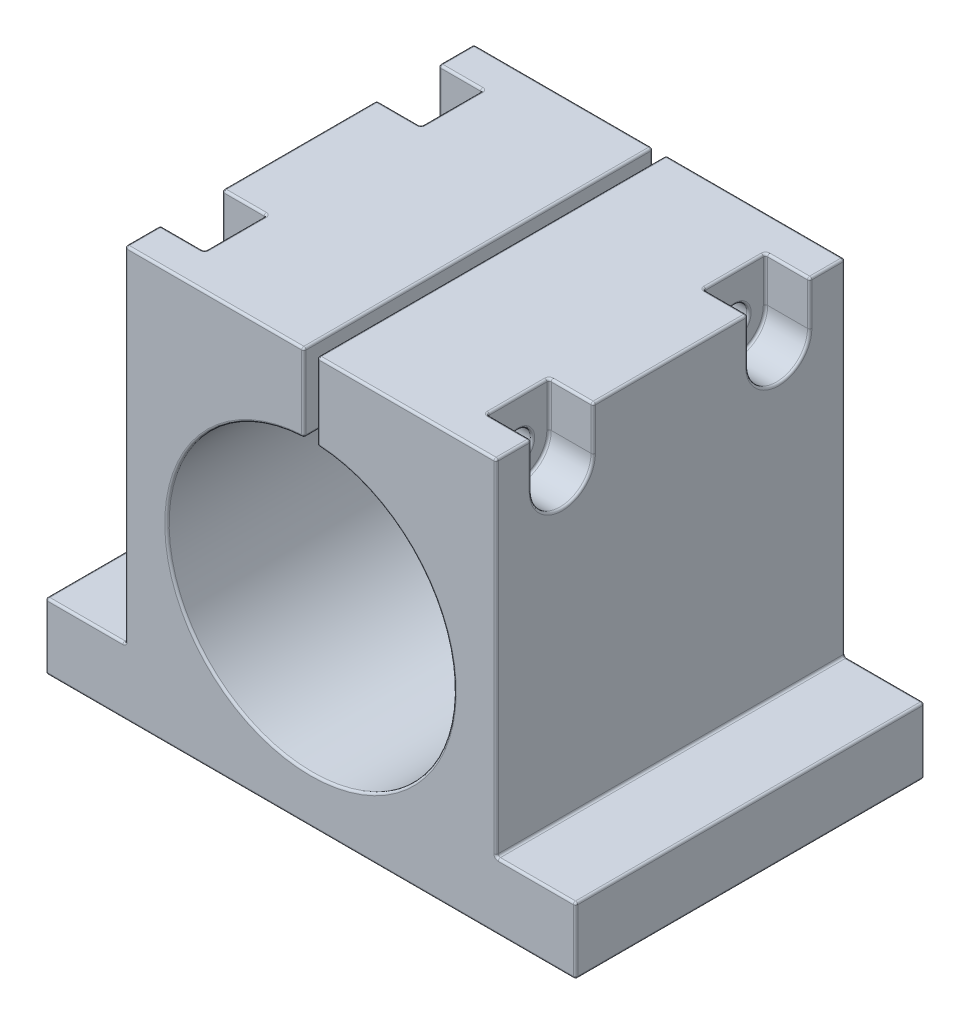
from build123d import *

# Parameters (mm, degrees)
EXTRUDE_1_DEPTH     = 39.5
CUT_EXTRUDE_1_DEPTH = 10
CUT_EXTRUDE_2_DEPTH = 10
SKETCH_4_R          = 3.25
CUT_EXTRUDE_3_DEPTH = 93
FILLET_1_R          = 0.5


with BuildPart() as part:
    # Эскиз1 → Бобышка-Вытянуть1 (new body, symmetric)
    with BuildSketch(Plane.XY):
        with BuildLine():
            Line((-60, -43), (60, -43))
            Line((60, -43), (60, -28))
            Line((60, -28), (42, -28))
            Line((42, -28), (42, 50))
            Line((42, 50), (1.5, 50))
            Line((1.5, 50), (1.5, 32.465366161))
            ThreePointArc((1.5, 32.465366161), (23.505318547, 22.444375687), (32.5, 0))
            ThreePointArc((32.5, 0), (-22.444375687, -23.505318547), (-1.5, 32.465366161))
            Line((-1.5, 32.465366161), (-1.5, 50))
            Line((-1.5, 50), (-42, 50))
            Line((-42, 50), (-42, -28))
            Line((-42, -28), (-60, -28))
            Line((-60, -28), (-60, -43))
        make_face()
    extrude(amount=EXTRUDE_1_DEPTH, both=True)

    # Эскиз2 → Вырез-Вытянуть1 (cut)
    with BuildSketch(Plane.ZY.offset(42)):
        with BuildLine():
            ThreePointArc((-17.5, 40), (-24.5, 47), (-31.5, 40))
            Line((-31.5, 40), (-17.5, 40))
        make_face()
        with BuildLine():
            Line((-17.5, 40), (-31.5, 40))
            ThreePointArc((-31.5, 40), (-24.5, 33), (-17.5, 40))
        make_face()
        with BuildLine():
            Line((-17.5, 50), (-31.5, 50))
            Line((-31.5, 50), (-31.5, 40))
            ThreePointArc((-31.5, 40), (-24.5, 47), (-17.5, 40))
            Line((-17.5, 40), (-17.5, 50))
        make_face()
        with BuildLine():
            ThreePointArc((31.5, 40), (24.5, 47), (17.5, 40))
            Line((17.5, 40), (31.5, 40))
        make_face()
        with BuildLine():
            Line((31.5, 40), (17.5, 40))
            ThreePointArc((17.5, 40), (24.5, 33), (31.5, 40))
        make_face()
        with BuildLine():
            ThreePointArc((31.5, 40), (24.5, 47), (17.5, 40))
            Line((17.5, 40), (31.5, 40))
        make_face()
        with BuildLine():
            Line((31.5, 40), (17.5, 40))
            ThreePointArc((17.5, 40), (24.5, 33), (31.5, 40))
        make_face()
        with BuildLine():
            Line((31.5, 50), (17.5, 50))
            Line((17.5, 50), (17.5, 40))
            ThreePointArc((17.5, 40), (24.5, 47), (31.5, 40))
            Line((31.5, 40), (31.5, 50))
        make_face()
    extrude(amount=-CUT_EXTRUDE_1_DEPTH, mode=Mode.SUBTRACT)

    # Эскиз3 → Вырез-Вытянуть2 (cut)
    with BuildSketch(Plane(origin=(42, 0, 0), x_dir=(0, 0, -1), z_dir=(1, 0, 0))):
        with BuildLine():
            Line((-31.5, 50), (-31.5, 40))
            ThreePointArc((-31.5, 40), (-24.5, 33), (-17.5, 40))
            Line((-17.5, 40), (-17.5, 50))
            Line((-17.5, 50), (-31.5, 50))
        make_face()
        with BuildLine():
            Line((17.5, 50), (17.5, 40))
            ThreePointArc((17.5, 40), (24.5, 33), (31.5, 40))
            Line((31.5, 40), (31.5, 50))
            Line((31.5, 50), (17.5, 50))
        make_face()
    extrude(amount=-CUT_EXTRUDE_2_DEPTH, mode=Mode.SUBTRACT)

    # Эскиз4 → Вырез-Вытянуть3 (cut, through all)
    with BuildSketch(Plane.ZY.offset(32)):
        with Locations((-24.5, 40)):
            Circle(SKETCH_4_R)
        with Locations((24.5, 40)):
            Circle(SKETCH_4_R)
    extrude(amount=-CUT_EXTRUDE_3_DEPTH, mode=Mode.SUBTRACT)

    # Скругление1
    fillet_1_edges = [part.edges().sort_by_distance(p)[0] for p in [
        (32, 40, 21.25),
        (-32, 40, 21.25),
        (1.5, 41.232683081, -39.5),
        (-21.75, 50, 39.5),
        (21.75, 50, -39.5),
        (42, 11, -39.5),
        (51, -28, -39.5),
        (60, -35.5, -39.5),
        (0, -43, -39.5),
        (-60, -35.5, -39.5),
        (-51, -28, -39.5),
        (-42, 11, -39.5),
        (-42, 11, 39.5),
        (-21.75, 50, -39.5),
        (-1.5, 41.232683081, -39.5),
        (0, -32.5, -39.5),
        (-51, -28, 39.5),
        (1.5, 32.465366161, 0),
        (1.5, 50, 0),
        (42, 50, 35.5),
        (42, -28, 0),
        (60, -28, 0),
        (60, -43, 0),
        (-60, -43, 0),
        (-60, -28, 0),
        (-42, -28, 0),
        (-42, 50, 35.5),
        (-1.5, 50, 0),
        (-1.5, 32.465366161, 0),
        (-60, -35.5, 39.5),
        (0, -43, 39.5),
        (60, -35.5, 39.5),
        (-42, 50, 0),
        (51, -28, 39.5),
        (-32, 33, 24.5),
        (-32, 45, 17.5),
        (-32, 50, 24.5),
        (-37, 50, 17.5),
        (-42, 45, 31.5),
        (42, 11, 39.5),
        (-37, 50, 31.5),
        (-32, 45, 31.5),
        (-42, 33, 24.5),
        (-42, 45, 17.5),
        (21.75, 50, 39.5),
        (1.5, 41.232683081, 39.5),
        (-42, 50, -35.5),
        (0, -32.5, 39.5),
        (-32, 33, -24.5),
        (-42, 33, -24.5),
        (-42, 45, -31.5),
        (-32, 45, -17.5),
        (-32, 50, -24.5),
        (-37, 50, -31.5),
        (-42, 45, -17.5),
        (-37, 50, -17.5),
        (-32, 45, -31.5),
        (42, 50, 0),
        (32, 33, 24.5),
        (32, 45, 31.5),
        (32, 50, 24.5),
        (37, 50, 31.5),
        (32, 45, 17.5),
        (37, 50, 17.5),
        (42, 33, 24.5),
        (42, 45, 17.5),
        (42, 45, 31.5),
        (42, 50, -35.5),
        (32, 33, -24.5),
        (32, 45, -17.5),
        (32, 50, -24.5),
        (37, 50, -17.5),
        (32, 45, -31.5),
        (37, 50, -31.5),
        (42, 33, -24.5),
        (42, 45, -31.5),
        (42, 45, -17.5),
        (-1.5, 41.232683081, 39.5),
        (32, 40, -27.75),
        (-32, 40, -27.75),
    ]]
    fillet(fillet_1_edges, radius=FILLET_1_R)


solid = part.part
